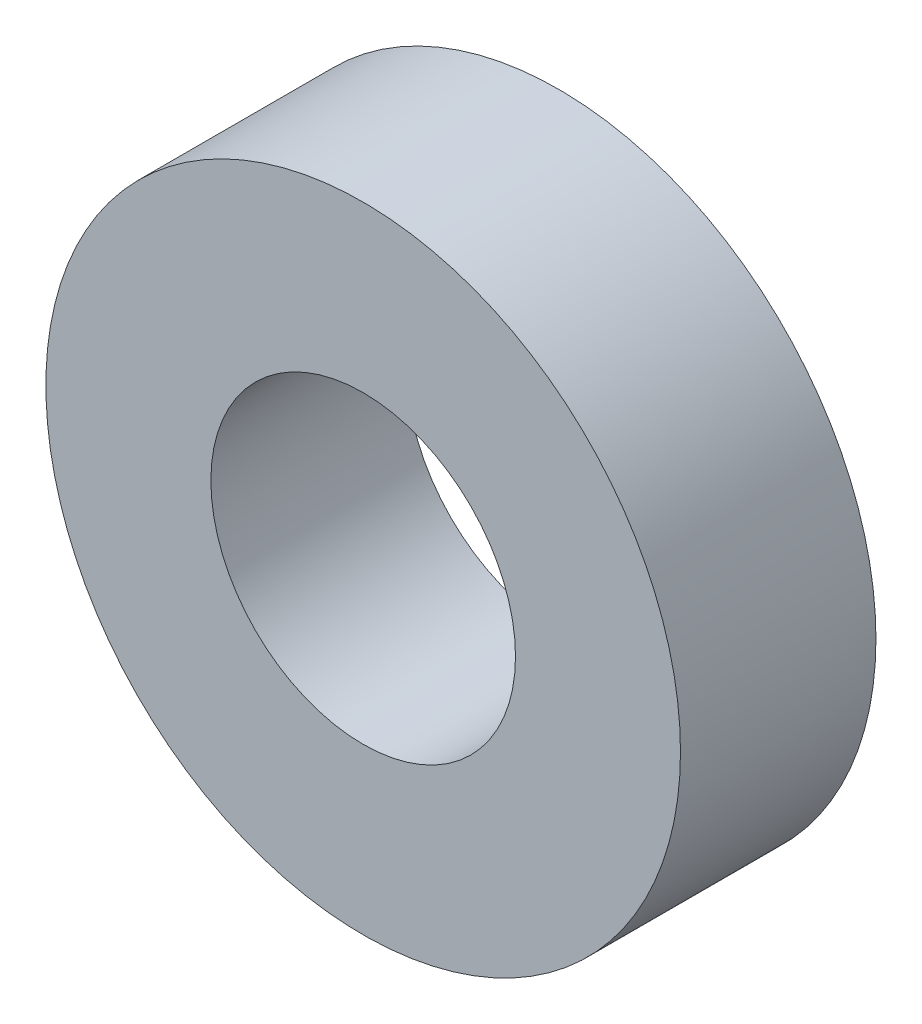
from build123d import *

# Parameters (mm, degrees)
SKETCH1_R      = 3.175
SKETCH1_R_2    = 1.524
EXTRUDE1_DEPTH = 1.9558


with BuildPart() as part:
    # Sketch1 → Extrude1 (new body)
    with BuildSketch(Plane.XY):
        Circle(SKETCH1_R)
        Circle(SKETCH1_R_2, mode=Mode.SUBTRACT)
    extrude(amount=-EXTRUDE1_DEPTH)


solid = part.part
